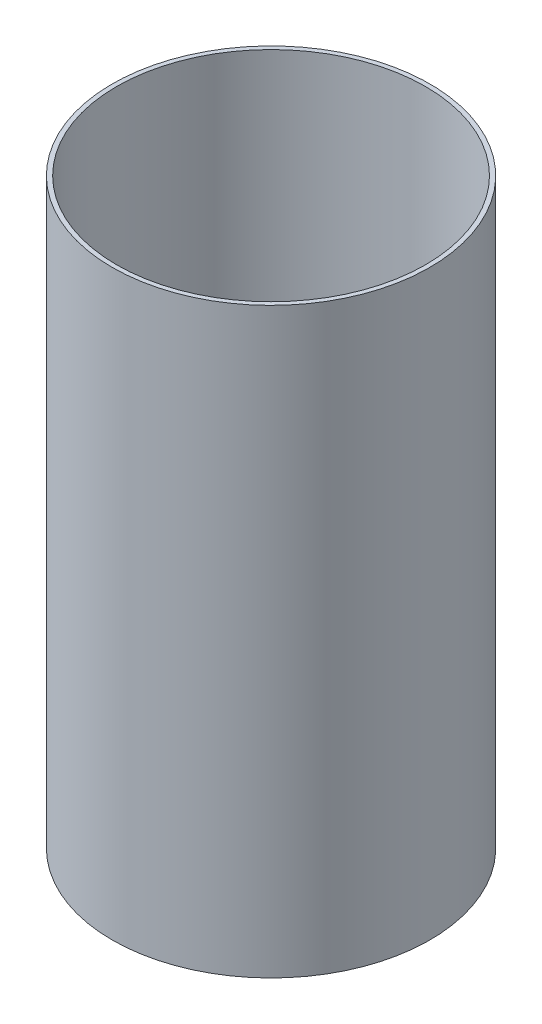
from build123d import *

# Parameters (mm, degrees)
SKETCH1_R           = 57.15
BOSS_EXTRUDE1_DEPTH = 209.55
SKETCH4_R           = 55.5625
CUT_EXTRUDE1_DEPTH  = 210.55


with BuildPart() as part:
    # Sketch1 → Boss-Extrude1 (new body)
    with BuildSketch(Plane(origin=(0, 0, 0), x_dir=(1, 0, 0), z_dir=(0, 1, 0))):
        Circle(SKETCH1_R)
    extrude(amount=BOSS_EXTRUDE1_DEPTH)

    # Sketch4 → Cut-Extrude1 (cut, through all)
    with BuildSketch(Plane.XZ):
        Circle(SKETCH4_R)
    extrude(amount=-CUT_EXTRUDE1_DEPTH, mode=Mode.SUBTRACT)


solid = part.part
